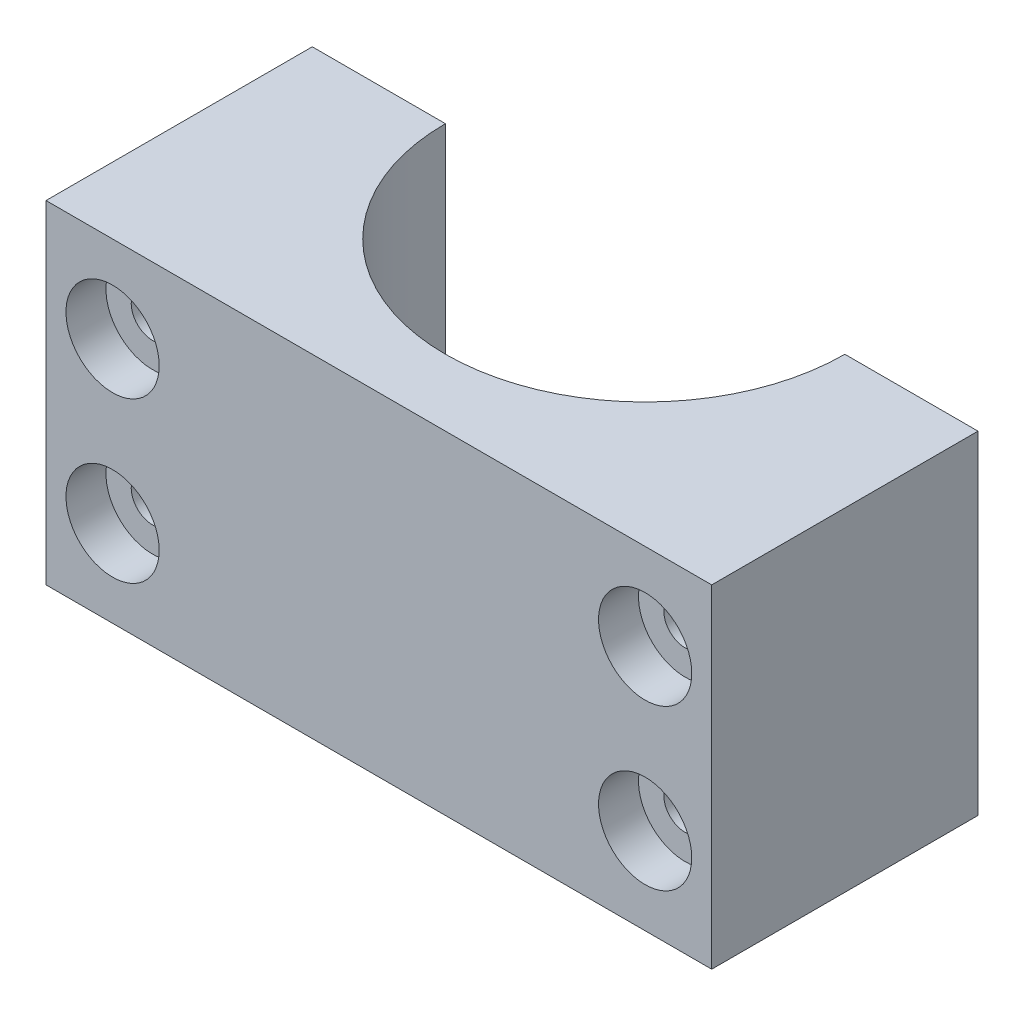
from build123d import *

# Parameters (mm, degrees)
BOSS_EXTRUDE1_DEPTH = 25
SKETCH2_R           = 4
CUT_EXTRUDE1_DEPTH  = 31
SKETCH3_R           = 1.6
CUT_EXTRUDE2_DEPTH  = 46
SKETCH4_W           = 10
SKETCH4_H           = 25
CUT_EXTRUDE3_DEPTH  = 26
SKETCH5_R           = 3.5
CUT_EXTRUDE4_DEPTH  = 3


with BuildPart() as part:
    # Sketch1 → Boss-Extrude1 (new body)
    with BuildSketch(Plane(origin=(0, 0, 0), x_dir=(1, 0, 0), z_dir=(0, 1, 0))):
        with BuildLine():
            Line((-14.972375691, 0), (-24.972375691, 0))
            Line((-24.972375691, 0), (-24.972375691, -20))
            Line((-24.972375691, -20), (-4.972375691, -20))
            Line((-4.972375691, -20), (-4.972375691, -45))
            Line((-4.972375691, -45), (5.027624309, -45))
            Line((5.027624309, -45), (5.027624309, -20))
            Line((5.027624309, -20), (25.027624309, -20))
            Line((25.027624309, -20), (25.027624309, 0))
            Line((25.027624309, 0), (15.027624309, 0))
            ThreePointArc((15.027624309, 0), (0.027624309, -15), (-14.972375691, 0))
        make_face()
    extrude(amount=BOSS_EXTRUDE1_DEPTH)

    # Sketch2 → Cut-Extrude1 (cut, through all)
    with BuildSketch(Plane.ZY.offset(4.972375691)):
        with Locations((36, 12.5)):
            Circle(SKETCH2_R)
    extrude(amount=-CUT_EXTRUDE1_DEPTH, mode=Mode.SUBTRACT)

    # Sketch3 → Cut-Extrude2 (cut, through all)
    with BuildSketch(Plane(origin=(0, 0, 0), x_dir=(-1, 0, 0), z_dir=(0, 0, -1))):
        with Locations((-20.027624309, 6.5)):
            Circle(SKETCH3_R)
        with Locations((-20.027624309, 18.5)):
            Circle(SKETCH3_R)
        with Locations((19.972375691, 6.5)):
            Circle(SKETCH3_R)
        with Locations((19.972375691, 18.5)):
            Circle(SKETCH3_R)
    extrude(amount=-CUT_EXTRUDE2_DEPTH, mode=Mode.SUBTRACT)

    # Sketch4 → Cut-Extrude3 (cut, through all)
    with BuildSketch(Plane(origin=(0, 25, 0), x_dir=(1, 0, 0), z_dir=(0, 1, 0))):
        with Locations((0.027624309, -32.5)):
            Rectangle(SKETCH4_W, SKETCH4_H)
    extrude(amount=-CUT_EXTRUDE3_DEPTH, mode=Mode.SUBTRACT)

    # Sketch5 → Cut-Extrude4 (cut)
    with BuildSketch(Plane.XY.offset(20)):
        with Locations((20.027624309, 18.5)):
            Circle(SKETCH5_R)
        with Locations((20.027624309, 6.5)):
            Circle(SKETCH5_R)
        with Locations((-19.972375691, 6.5)):
            Circle(SKETCH5_R)
        with Locations((-19.972375691, 18.5)):
            Circle(SKETCH5_R)
    extrude(amount=-CUT_EXTRUDE4_DEPTH, mode=Mode.SUBTRACT)


solid = part.part
